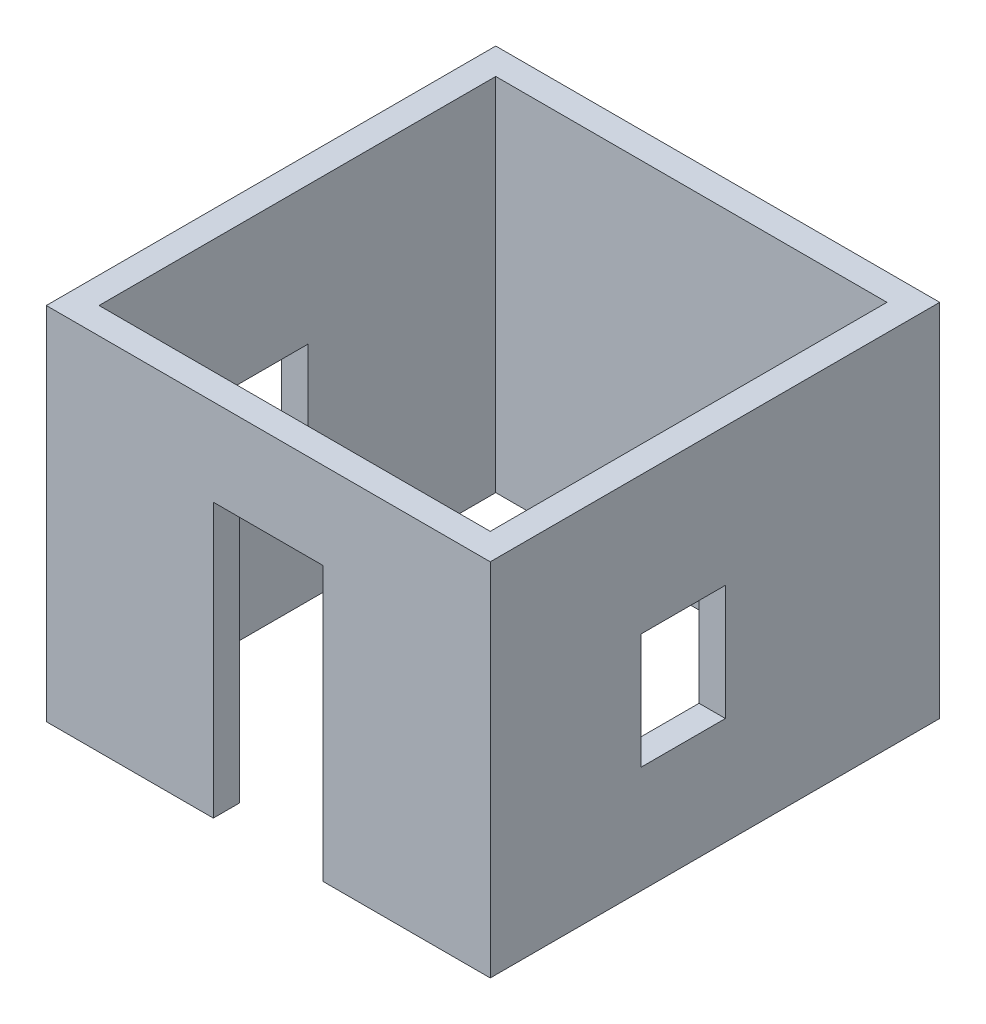
from build123d import *

# Parameters (mm, degrees)
SKETCH_1_W                 = 4040
SKETCH_1_H                 = 4090
SKETCH_1_W_2               = 3560
SKETCH_1_H_2               = 3610
EXTRUDE_293_DEPTH          = 3280
SKETCH_3_W                 = 770
SKETCH_3_H                 = 1960
CUT_EXTRUDE_510_DEPTH      = 241
SKETCH_4_W                 = 1000
SKETCH_4_H                 = 2490
CUT_EXTRUDE_703_DEPTH      = 241
SKETCH_5_W                 = 770
SKETCH_5_H                 = 1050
CUT_EXTRUDE_922_DEPTH      = 3801
CUT_EXTRUDE_922_DEPTH_BACK = 241


with BuildPart() as part:
    # 草图1 → Extrude 293 (new body)
    with BuildSketch(Plane(origin=(0, 0, 0), x_dir=(1, 0, 0), z_dir=(0, 1, 0))):
        Rectangle(SKETCH_1_W, SKETCH_1_H)
        Rectangle(SKETCH_1_W_2, SKETCH_1_H_2, mode=Mode.SUBTRACT)
    extrude(amount=EXTRUDE_293_DEPTH)

    # 草图3 → Cut-Extrude 510 (cut, through all)
    with BuildSketch(Plane.XY.offset(-1805)):
        with Locations((1135, 980)):
            Rectangle(SKETCH_3_W, SKETCH_3_H)
    extrude(amount=-CUT_EXTRUDE_510_DEPTH, mode=Mode.SUBTRACT)

    # 草图4 → Cut-Extrude 703 (cut, through all)
    with BuildSketch(Plane(origin=(0, 0, 1805), x_dir=(-1, 0, 0), z_dir=(0, 0, -1))):
        with Locations((0, 1245)):
            Rectangle(SKETCH_4_W, SKETCH_4_H)
    extrude(amount=-CUT_EXTRUDE_703_DEPTH, mode=Mode.SUBTRACT)

    # 草图5 → Cut-Extrude 922 (cut, two sides)
    with BuildSketch(Plane(origin=(-1780, 0, 0), x_dir=(0, 0, -1), z_dir=(1, 0, 0))) as cut_extrude_922_sk:
        with Locations((-290, 1500)):
            Rectangle(SKETCH_5_W, SKETCH_5_H)
    extrude(amount=CUT_EXTRUDE_922_DEPTH, mode=Mode.SUBTRACT)
    extrude(cut_extrude_922_sk.sketch, amount=-CUT_EXTRUDE_922_DEPTH_BACK, mode=Mode.SUBTRACT)


solid = part.part
